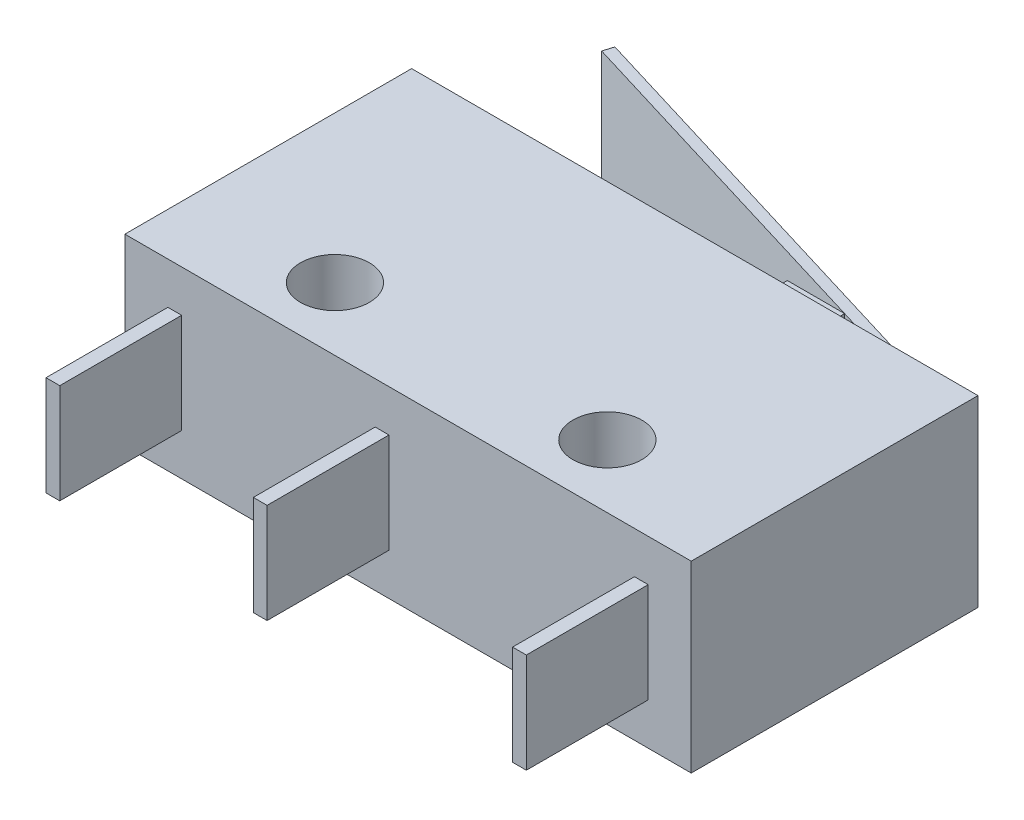
from build123d import *

# Parameters (mm, degrees)
SKETCH2_W                  = 19.75
SKETCH2_H                  = 10
SKETCH2_R                  = 1.2
BOSS_EXTRUDE1_DEPTH        = 6.4
SKETCH3_W                  = 0.48
SKETCH3_H                  = 3.48
BOSS_EXTRUDE2_DEPTH        = 4.25
SKETCH4_W                  = 2
SKETCH4_H                  = 1.35
BOSS_EXTRUDE4_DEPTH        = 2
BOSS_EXTRUDE4_DEPTH_BACK   = 2
BOSS_EXTRUDE4_2_DEPTH      = 2
BOSS_EXTRUDE4_2_DEPTH_BACK = 2


with BuildPart() as part:
    # Sketch2 → Boss-Extrude1 (new body)
    with BuildSketch(Plane(origin=(0, 0, 0), x_dir=(1, 0, 0), z_dir=(0, 1, 0))):
        with Locations((9.875, 5)):
            Rectangle(SKETCH2_W, SKETCH2_H)
        with Locations((5.125, 2.2)):
            Circle(SKETCH2_R, mode=Mode.SUBTRACT)
        with Locations((14.625, 2.2)):
            Circle(SKETCH2_R, mode=Mode.SUBTRACT)
    extrude(amount=BOSS_EXTRUDE1_DEPTH)

    # Sketch3 → Boss-Extrude2 (add)
    with BuildSketch(Plane.XY):
        with Locations((1.74, 3.2)):
            Rectangle(SKETCH3_W, SKETCH3_H)
        with Locations((8.97, 3.2)):
            Rectangle(SKETCH3_W, SKETCH3_H)
        with Locations((18.01, 3.2)):
            Rectangle(SKETCH3_W, SKETCH3_H)
    extrude(amount=BOSS_EXTRUDE2_DEPTH)


with BuildPart() as body_2:
    # Sketch4 → Boss-Extrude4 (new body, two sides)
    with BuildSketch(Plane(origin=(0, 3.2, 0), x_dir=(1, 0, 0), z_dir=(0, 1, 0))) as boss_extrude4_sk:
        with Locations((12.75, 10.675)):
            Rectangle(SKETCH4_W, SKETCH4_H)
    extrude(amount=BOSS_EXTRUDE4_DEPTH)
    extrude(boss_extrude4_sk.sketch, amount=-BOSS_EXTRUDE4_DEPTH_BACK)


with BuildPart() as body_3:
    # Sketch4 → Boss-Extrude4 2 (new body, two sides)
    with BuildSketch(Plane(origin=(0, 3.2, 0), x_dir=(1, 0, 0), z_dir=(0, 1, 0))) as boss_extrude4_2_sk:
        Polygon((16.63, 10.475653818), (1.582515124, 15.04395623), (1.690000124, 15.397999977), (17, 10.75), (17, 10), (16.63, 10), align=None)
    extrude(amount=BOSS_EXTRUDE4_2_DEPTH)
    extrude(boss_extrude4_2_sk.sketch, amount=-BOSS_EXTRUDE4_2_DEPTH_BACK)


solid = Compound([part.part, body_2.part, body_3.part])
